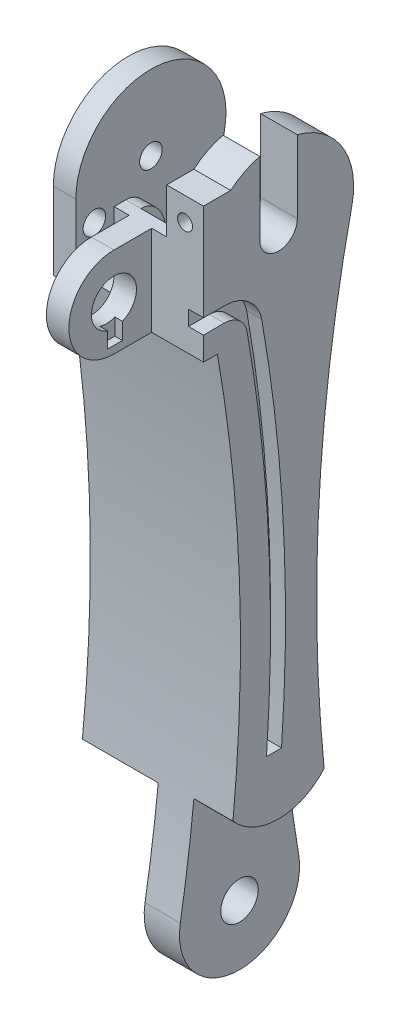
from build123d import *

# Parameters (mm, degrees)
SKETCH1_R                = 1.5
SKETCH1_R_2              = 2.5
BOSS_EXTRUDE1_DEPTH      = 20
SKETCH2_W                = 8.1
SKETCH2_H                = 20
SKETCH2_W_2              = 5.2
SKETCH2_W_3              = 5.1
CUT_EXTRUDE1_DEPTH       = 20
CUT_EXTRUDE1_DEPTH_BACK  = 20
CUT_EXTRUDE2_DEPTH       = 9
BOSS_EXTRUDE2_DEPTH      = 11.9
SKETCH5_R                = 3
BOSS_EXTRUDE3_DEPTH      = 5
CUT_EXTRUDE6_DEPTH       = 1
SKETCH13_R               = 2.5
CUT_EXTRUDE7_DEPTH       = 4
BOSS_EXTRUDE4_DEPTH      = 3
CUT_EXTRUDE9_DEPTH       = 3
SKETCH17_W               = 9
SKETCH17_H               = 3.569322199
CUT_EXTRUDE11_DEPTH      = 3
SKETCH18_W               = 5.770974844
SKETCH18_H               = 0.772936936
BOSS_EXTRUDE5_DEPTH      = 6.9
BOSS_EXTRUDE5_DEPTH_BACK = 1
SKETCH19_W               = 5.1
SKETCH19_H               = 16.397725614
CUT_EXTRUDE12_DEPTH      = 0.301495
SKETCH20_W               = 5
SKETCH20_H               = 12.419235667
CUT_EXTRUDE13_DEPTH      = 10
BOSS_EXTRUDE6_DEPTH      = 2
SKETCH23_W               = 4.9
SKETCH23_H               = 6
BOSS_EXTRUDE7_DEPTH      = 4
SKETCH22_R               = 1
CUT_EXTRUDE15_DEPTH      = 8
BOSS_EXTRUDE8_DEPTH      = 2
SKETCH14_R               = 1.5
CUT_EXTRUDE8_DEPTH       = 10.1
CUT_EXTRUDE17_DEPTH      = 8.1
CUT_EXTRUDE17_DEPTH_BACK = 2
CUT_EXTRUDE18_DEPTH      = 2
CUT_EXTRUDE20_DEPTH      = 5.2
SKETCH30_W               = 6.9
SKETCH30_H               = 20
CUT_EXTRUDE21_DEPTH      = 0.283797
CUT_EXTRUDE22_REACH      = 91.699
SKETCH31_W               = 2
SKETCH31_H               = 11.022421386
CUT_EXTRUDE23_DEPTH      = 7


with BuildPart() as part:
    # Sketch1 → Boss-Extrude1 (new body)
    with BuildSketch(Plane(origin=(0, 0, 0), x_dir=(0, 0, -1), z_dir=(1, 0, 0))):
        with BuildLine():
            ThreePointArc((9.765353557, 20.116545894), (0, 32.270117322), (-9.765353557, 20.116545894))
            ThreePointArc((-9.765353557, 20.116545894), (-5.132645827, -18.047253777), (-7.88740095, -56.392382678))
            ThreePointArc((-7.88740095, -56.392382678), (0, -65.729882678), (7.88740095, -56.392382678))
            ThreePointArc((7.88740095, -56.392382678), (5.132645827, -18.047253777), (9.765353557, 20.116545894))
        make_face()
        with Locations((0, 22.270117322)):
            Circle(SKETCH1_R, mode=Mode.SUBTRACT)
        with Locations((0, -57.729882678)):
            Circle(SKETCH1_R_2, mode=Mode.SUBTRACT)
    extrude(amount=BOSS_EXTRUDE1_DEPTH)

    # Sketch2 → Cut-Extrude1 (cut, two sides)
    with BuildSketch(Plane.XY) as cut_extrude1_sk:
        with Locations((4.05, -55.729882678)):
            Rectangle(SKETCH2_W, SKETCH2_H)
        with Locations((17.4, -55.729882678)):
            Rectangle(SKETCH2_W_2, SKETCH2_H)
        with Locations((5.55, 22.270117322)):
            Rectangle(SKETCH2_W_3, SKETCH2_H)
    extrude(amount=CUT_EXTRUDE1_DEPTH, mode=Mode.SUBTRACT)
    extrude(cut_extrude1_sk.sketch, amount=-CUT_EXTRUDE1_DEPTH_BACK, mode=Mode.SUBTRACT)

    # Sketch3 → Cut-Extrude2 (cut)
    with BuildSketch(Plane.ZY.offset(-8.1)):
        with BuildLine():
            Line((8.5, 22.270117322), (8.5, 40.909533312))
            Line((8.5, 40.909533312), (-17.52872033, 40.909533312))
            Line((-17.52872033, 40.909533312), (-17.52872033, 13.770117322))
            Line((-17.52872033, 13.770117322), (0, 13.770117322))
            ThreePointArc((0, 13.770117322), (6.01040764, 16.259709682), (8.5, 22.270117322))
        make_face()
    extrude(amount=-CUT_EXTRUDE2_DEPTH, mode=Mode.SUBTRACT)

    # Sketch4 → Boss-Extrude2 (add, through all)
    with BuildSketch(Plane.ZY.offset(-8.1)):
        Polygon((8.5, 27.537944199), (8.283796844, 12.741558936), (10.283796844, 12.741558936), (10.283796844, 27.537944199), align=None)
    extrude(amount=-BOSS_EXTRUDE2_DEPTH)

    # Sketch5 → Boss-Extrude3 (add)
    with BuildSketch(Plane.ZY.offset(-8.1)):
        with BuildLine():
            Line((8.145156861, 11.968622), (8.447845456, 23.968622))
            Line((8.447845456, 23.968622), (9.854698466, 23.968622))
            Line((9.854698466, 23.968622), (15.022421386, 23.968622))
            ThreePointArc((15.022421386, 23.968622), (21.022421386, 17.968622), (15.022421386, 11.968622))
            Line((15.022421386, 11.968622), (8.145156861, 11.968622))
        make_face()
        with Locations((15.022421386, 17.968622)):
            Circle(SKETCH5_R, mode=Mode.SUBTRACT)
    extrude(amount=-BOSS_EXTRUDE3_DEPTH)

    # Sketch12 → Cut-Extrude6 (cut)
    with BuildSketch(Plane(origin=(13.1, 0, 0), x_dir=(0, 0, -1), z_dir=(1, 0, 0))):
        Polygon((-13.902900694, 14.968622), (-13.902900694, 12.968622), (-15.902900694, 12.968622), (-15.902900694, 14.968622), (-15.902900694, 15.294296094), (-13.902900694, 15.294296094), align=None)
    extrude(amount=-CUT_EXTRUDE6_DEPTH, mode=Mode.SUBTRACT)

    # Sketch13 → Cut-Extrude7 (cut)
    with BuildSketch(Plane.ZY.offset(-17.1)):
        with Locations((0, 22.270117322)):
            Circle(SKETCH13_R)
    extrude(amount=-CUT_EXTRUDE7_DEPTH, mode=Mode.SUBTRACT)

    # Sketch15 → Boss-Extrude4 (add)
    with BuildSketch(Plane.ZY):
        Polygon((10, 22.270117322), (10, 11.968622), (8.145156861, 11.968622), (7.595672539, 11.968622), align=None)
    extrude(amount=-BOSS_EXTRUDE4_DEPTH)

    # Sketch16 → Cut-Extrude9 (cut)
    with BuildSketch(Plane(origin=(20, 0, 0), x_dir=(0, 0, -1), z_dir=(1, 0, 0))):
        with BuildLine():
            Line((-10.283796844, 23.968622), (-9.854698466, 23.968622))
            ThreePointArc((-9.854698466, 23.968622), (-9.349264901, 25.818531871), (-8.5, 27.537944199))
            Line((-8.5, 27.537944199), (-10.283796844, 27.537944199))
            Line((-10.283796844, 27.537944199), (-10.283796844, 23.968622))
        make_face()
    extrude(amount=-CUT_EXTRUDE9_DEPTH, mode=Mode.SUBTRACT)

    # Sketch17 → Cut-Extrude11 (cut)
    with BuildSketch(Plane.XY.offset(10.283796844)):
        with Locations((12.6, 25.7532831)):
            Rectangle(SKETCH17_W, SKETCH17_H)
    extrude(amount=-CUT_EXTRUDE11_DEPTH, mode=Mode.SUBTRACT)

    # Sketch18 → Boss-Extrude5 (add, two sides)
    with BuildSketch(Plane(origin=(13.1, 0, 0), x_dir=(0, 0, -1), z_dir=(1, 0, 0))) as boss_extrude5_sk:
        with Locations((-7.398309422, 12.355090468)):
            Rectangle(SKETCH18_W, SKETCH18_H)
    extrude(amount=BOSS_EXTRUDE5_DEPTH)
    extrude(boss_extrude5_sk.sketch, amount=-BOSS_EXTRUDE5_DEPTH_BACK)

    # Sketch19 → Cut-Extrude12 (cut)
    with BuildSketch(Plane(origin=(0, 12.270117322, 0), x_dir=(1, 0, 0), z_dir=(0, 1, 0))):
        with Locations((5.55, 0)):
            Rectangle(SKETCH19_W, SKETCH19_H)
    extrude(amount=-CUT_EXTRUDE12_DEPTH, mode=Mode.SUBTRACT)

    # Sketch20 → Cut-Extrude13 (cut)
    with BuildSketch(Plane.ZY.offset(-17.1)):
        with Locations((0, 28.479735156)):
            Rectangle(SKETCH20_W, SKETCH20_H)
    extrude(amount=-CUT_EXTRUDE13_DEPTH, mode=Mode.SUBTRACT)

    # Sketch21 → Boss-Extrude6 (add)
    with BuildSketch(Plane.ZY.offset(-17.1)):
        with BuildLine():
            Line((-8.473151119, 13.770117322), (0.278481736, 12.273995678))
            ThreePointArc((0.278481736, 12.273995678), (9.936881703, 21.148341047), (2.5, 31.952575688))
            Line((2.5, 31.952575688), (2.5, 22.270117322))
            ThreePointArc((2.5, 22.270117322), (0, 19.770117322), (-2.5, 22.270117322))
            Line((-2.5, 22.270117322), (-2.5, 31.952575688))
            ThreePointArc((-2.5, 31.952575688), (-8.522477621, 27.501501002), (-9.765353557, 20.116545894))
            ThreePointArc((-9.765353557, 20.116545894), (-9.093560923, 16.948562662), (-8.473151119, 13.770117322))
        make_face()
    extrude(amount=BOSS_EXTRUDE6_DEPTH)

    # Sketch23 → Boss-Extrude7 (add)
    with BuildSketch(Plane.XY.offset(10.283796844)):
        with Locations((17.55, 26.968622)):
            Rectangle(SKETCH23_W, SKETCH23_H)
    extrude(amount=-BOSS_EXTRUDE7_DEPTH)

    # Sketch22 → Cut-Extrude15 (cut)
    with BuildSketch(Plane.XY.offset(10.283796844)):
        with Locations((17.55, 26.870117322)):
            Circle(SKETCH22_R)
    extrude(amount=-CUT_EXTRUDE15_DEPTH, mode=Mode.SUBTRACT)

    # Sketch24 → Boss-Extrude8 (add)
    with BuildSketch(Plane.ZY.offset(-8.1)):
        with BuildLine():
            Line((5.147845456, 19.737443909), (5.147845456, 15.506265819))
            Line((5.147845456, 15.506265819), (8.447845456, 15.506265819))
            Line((8.447845456, 15.506265819), (8.447845456, 23.968622))
            add(Edge.make_bspline(
                [(8.447845456, 23.968622), (5.147845456, 23.968622), (5.147845456, 19.737443909)],
                knots=[3.141592654, 3.141592654, 3.141592654, 4.71238898, 4.71238898, 4.71238898], degree=2, weights=[1, 0.707106781, 1]))
        make_face()
    extrude(amount=-BOSS_EXTRUDE8_DEPTH)

    # Sketch14 → Cut-Extrude8 (cut)
    with BuildSketch(Plane.ZY):
        with Locations((7.532575614, 18.331804915)):
            Circle(SKETCH14_R)
    extrude(amount=-CUT_EXTRUDE8_DEPTH, mode=Mode.SUBTRACT)

    # Sketch25 → Cut-Extrude17 (cut, two sides)
    with BuildSketch(Plane.ZY.offset(-8.1)) as cut_extrude17_sk:
        with BuildLine():
            Line((12, -45.729882678), (8.346153846, -36.960651908))
            ThreePointArc((8.346153846, -36.960651908), (6.973852263, -42.37911752), (2.5, -45.729882678))
            Line((2.5, -45.729882678), (2.5, -53.227383372))
            ThreePointArc((2.5, -53.227383372), (0, -62.879882678), (-2.5, -53.227383372))
            Line((-2.5, -53.227383372), (-2.5, -45.729882678))
            ThreePointArc((-2.5, -45.729882678), (-6.973852263, -42.37911752), (-8.346153846, -36.960651908))
            Line((-8.346153846, -36.960651908), (-12, -45.729882678))
            Line((-12, -45.729882678), (-12, -57.729882678))
            ThreePointArc((-12, -57.729882678), (0, -69.729882678), (12, -57.729882678))
            Line((12, -57.729882678), (12, -45.729882678))
        make_face()
    extrude(amount=CUT_EXTRUDE17_DEPTH, mode=Mode.SUBTRACT)
    extrude(cut_extrude17_sk.sketch, amount=-CUT_EXTRUDE17_DEPTH_BACK, mode=Mode.SUBTRACT)

    # Sketch26 → Cut-Extrude18 (cut)
    with BuildSketch(Plane(origin=(20, 0, 0), x_dir=(0, 0, -1), z_dir=(1, 0, 0))):
        with BuildLine():
            Line((-7.209968303, 15.085404497), (-10.283796844, 15.085404497))
            Line((-10.283796844, 15.085404497), (-10.283796844, 17.085404497))
            Line((-10.283796844, 17.085404497), (-7.209968303, 17.085404497))
            ThreePointArc((-7.209968303, 17.085404497), (-4.010444351, 15.949526558), (-2.243391617, 13.050441039))
            ThreePointArc((-2.243391617, 13.050441039), (0.649659998, -12.257973546), (0.397031114, -37.729953741))
            Line((0.397031114, -37.729953741), (-1.608183929, -37.729953741))
            ThreePointArc((-1.608183929, -37.729953741), (-1.343036313, -12.450773719), (-4.206611504, 12.667092093))
            ThreePointArc((-4.206611504, 12.667092093), (-5.281990934, 14.405678614), (-7.209968303, 15.085404497))
        make_face()
    extrude(amount=-CUT_EXTRUDE18_DEPTH, mode=Mode.SUBTRACT)

    # Sketch29 → Cut-Extrude20 (cut)
    with BuildSketch(Plane(origin=(20, 0, 0), x_dir=(0, 0, -1), z_dir=(1, 0, 0))):
        with BuildLine():
            Line((8, -37.729882678), (8.140336581, -37.729882678))
            Line((8.140336581, -37.729882678), (8.140336581, -45.937498976))
            Line((8.140336581, -45.937498976), (-15.754893946, -45.937498976))
            Line((-15.754893946, -45.937498976), (-15.754893946, -37.729882678))
            Line((-15.754893946, -37.729882678), (-8, -37.729882678))
            ThreePointArc((-8, -37.729882678), (0, -45.729882678), (8, -37.729882678))
        make_face()
    extrude(amount=-CUT_EXTRUDE20_DEPTH, mode=Mode.SUBTRACT)

    # Sketch30 → Cut-Extrude21 (cut)
    with BuildSketch(Plane.XY.offset(10.283796844)):
        with Locations((16.55, 21.968622)):
            Rectangle(SKETCH30_W, SKETCH30_H)
    extrude(amount=-CUT_EXTRUDE21_DEPTH, mode=Mode.SUBTRACT)

    # Sketch31 → Cut-Extrude22 (cut, up to next)
    with BuildSketch(Plane(origin=(0, 23.968622, 0), x_dir=(1, 0, 0), z_dir=(0, 1, 0)), mode=Mode.PRIVATE) as cut_extrude22_sk1:
        with Locations((9.1, -15.511210693)):
            Rectangle(SKETCH31_W, SKETCH31_H)
    cut_extrude22_tool1 = extrude(cut_extrude22_sk1.sketch, amount=-CUT_EXTRUDE22_REACH, mode=Mode.PRIVATE) & part.part
    add(cut_extrude22_tool1.solids().sort_by_distance((9.1, 23.968622, 15.511211))[0], mode=Mode.SUBTRACT)

    # Sketch32 → Cut-Extrude23 (cut)
    with BuildSketch(Plane.ZY.offset(-8.1)):
        Polygon((-8.473151119, 13.770117322), (-8.473151119, 5.401068454), (5.147845456, 15.506265819), align=None)
    extrude(amount=-CUT_EXTRUDE23_DEPTH, mode=Mode.SUBTRACT)


solid = part.part
